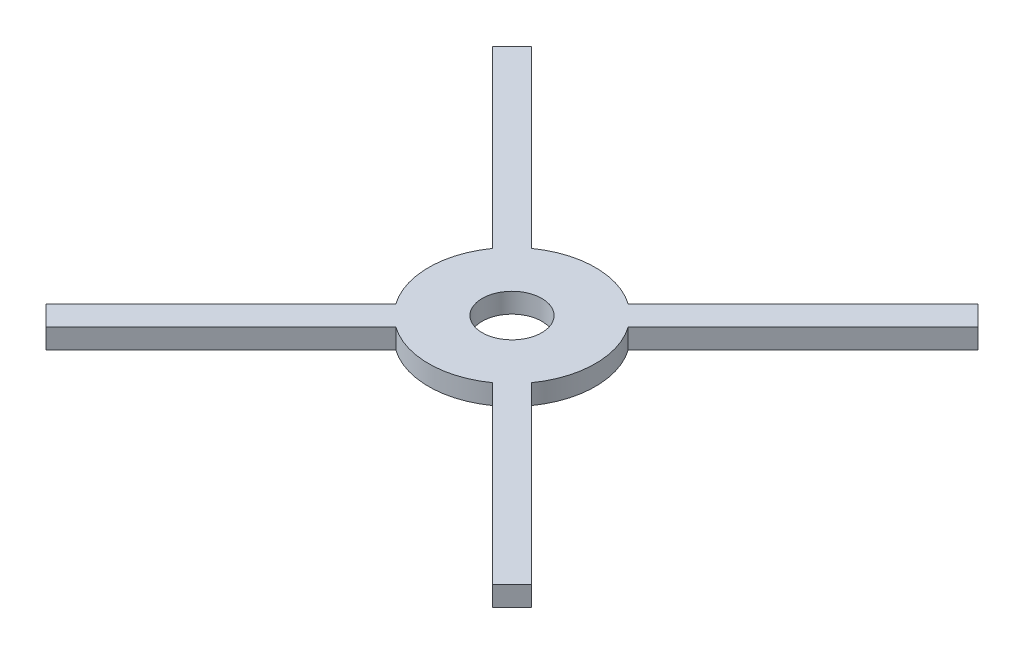
from build123d import *

# Parameters (mm, degrees)
SKETCH_1_R      = 7.5
EXTRUDE_1_DEPTH = 5


with BuildPart() as part:
    # Эскиз1 → Бобышка-Вытянуть1 (new body)
    with BuildSketch(Plane(origin=(0, 0, 0), x_dir=(1, 0, 0), z_dir=(0, 1, 0))):
        with BuildLine():
            Line((-17.116424198, -12.16667673), (-61.179242059, -56.229494591))
            Line((-61.179242059, -56.229494591), (-56.229494591, -61.179242059))
            Line((-56.229494591, -61.179242059), (-12.16667673, -17.116424198))
            ThreePointArc((-12.16667673, -17.116424198), (0, -21), (12.16667673, -17.116424198))
            Line((12.16667673, -17.116424198), (56.229494591, -61.179242059))
            Line((56.229494591, -61.179242059), (61.179242059, -56.229494591))
            Line((61.179242059, -56.229494591), (17.116424198, -12.16667673))
            ThreePointArc((17.116424198, -12.16667673), (21, 0), (17.116424198, 12.16667673))
            Line((17.116424198, 12.16667673), (61.179242059, 56.229494591))
            Line((61.179242059, 56.229494591), (56.229494591, 61.179242059))
            Line((56.229494591, 61.179242059), (12.16667673, 17.116424198))
            ThreePointArc((12.16667673, 17.116424198), (0, 21), (-12.16667673, 17.116424198))
            Line((-12.16667673, 17.116424198), (-56.229494591, 61.179242059))
            Line((-56.229494591, 61.179242059), (-61.179242059, 56.229494591))
            Line((-61.179242059, 56.229494591), (-17.116424198, 12.16667673))
            ThreePointArc((-17.116424198, 12.16667673), (-21, 0), (-17.116424198, -12.16667673))
        make_face()
        Circle(SKETCH_1_R, mode=Mode.SUBTRACT)
    extrude(amount=EXTRUDE_1_DEPTH)


solid = part.part
